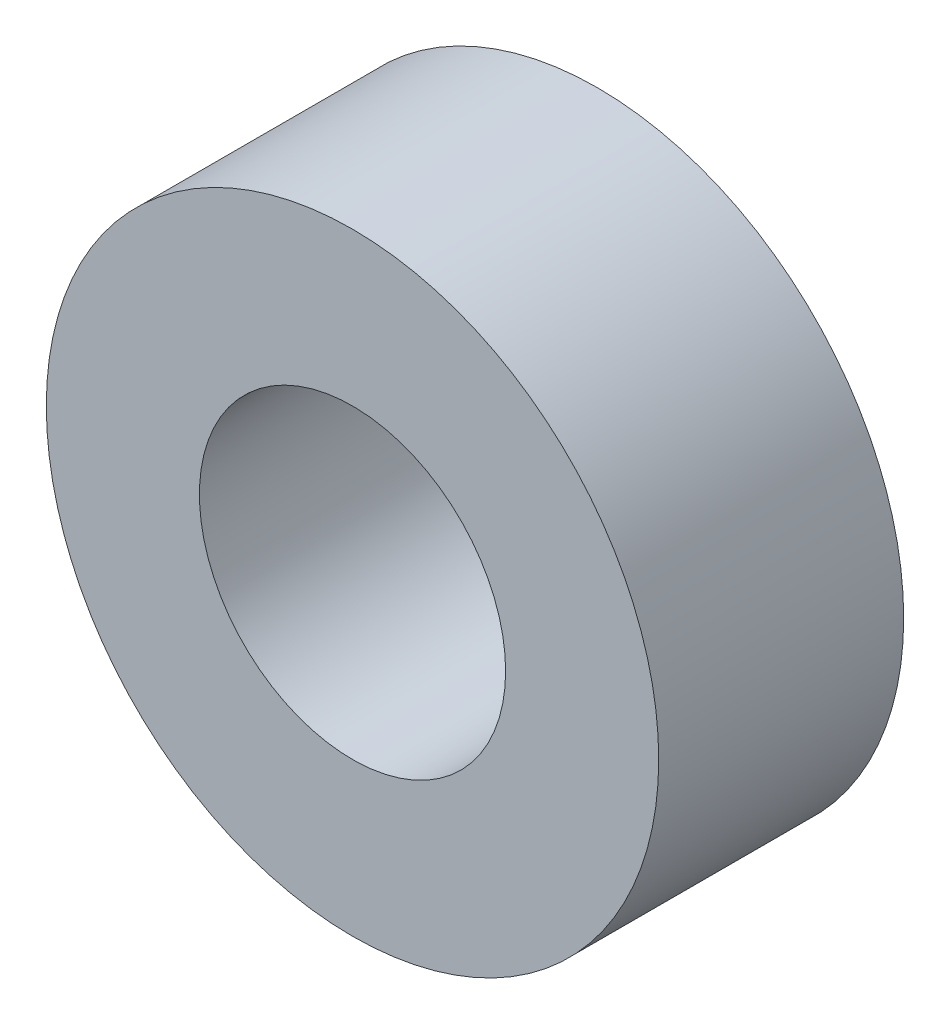
from build123d import *

# Parameters (mm, degrees)
SKETCH1_R           = 5
SKETCH1_R_2         = 2.5
BOSS_EXTRUDE1_DEPTH = 4


with BuildPart() as part:
    # Sketch1 → Boss-Extrude1 (new body)
    with BuildSketch(Plane.XY):
        Circle(SKETCH1_R)
        Circle(SKETCH1_R_2, mode=Mode.SUBTRACT)
    extrude(amount=BOSS_EXTRUDE1_DEPTH)


solid = part.part
